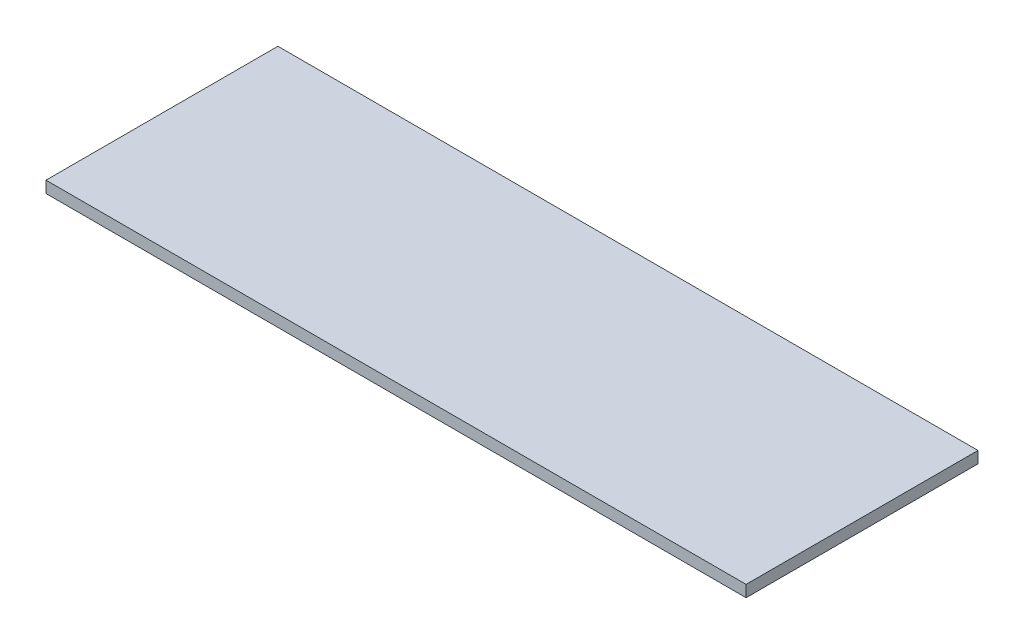
from build123d import *

# Parameters (mm, degrees)
SKETCH1_W           = 1150
SKETCH1_H           = 380.95
BOSS_EXTRUDE1_DEPTH = 19.05


with BuildPart() as part:
    # Sketch1 → Boss-Extrude1 (new body)
    with BuildSketch(Plane(origin=(0, 0, 0), x_dir=(1, 0, 0), z_dir=(0, 1, 0))):
        with Locations((575, -190.475)):
            Rectangle(SKETCH1_W, SKETCH1_H)
    extrude(amount=BOSS_EXTRUDE1_DEPTH)


solid = part.part
